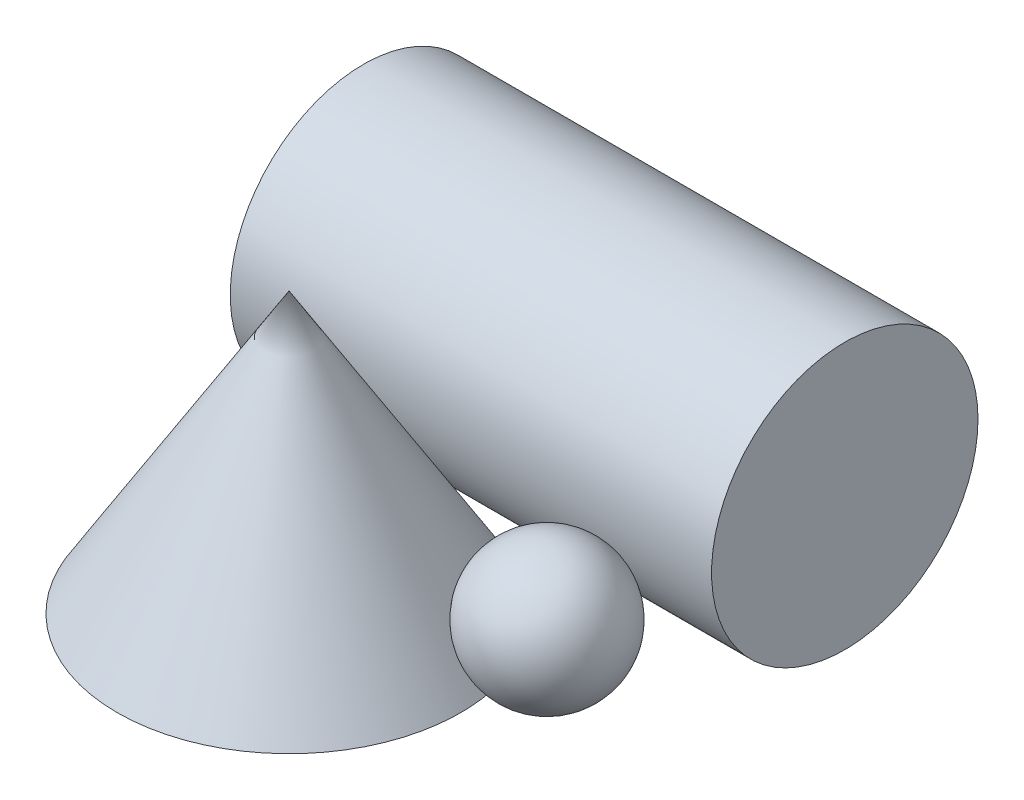
from build123d import *

# Parameters (mm, degrees)
SKETCH2_R           = 31
EXTRUDE1_DEPTH      = 72
EXTRUDE1_DEPTH_BACK = 40


with BuildPart() as part:
    # Sketch1 → Revolve1 (revolve)
    with BuildSketch(Plane.XY, mode=Mode.PRIVATE) as revolve1_sk:
        Polygon((40, 0), (0, 0), (0, 65), align=None)
    revolve(revolve1_sk.sketch.rotate(Axis((0, 0, 0), (0, 1, 0)), 90), axis=Axis((0, 0, 0), (0, 1, 0)))  # turned: the seam where the file's is


with BuildPart() as body_2:
    # Sketch2 → Extrude1 (new body, two sides)
    with BuildSketch(Plane(origin=(0, 0, 0), x_dir=(0, 0, -1), z_dir=(1, 0, 0))) as extrude1_sk:
        with Locations((57.322651015, 31)):
            Circle(SKETCH2_R)
    extrude(amount=EXTRUDE1_DEPTH)
    extrude(extrude1_sk.sketch, amount=-EXTRUDE1_DEPTH_BACK)


with BuildPart() as body_3:
    # Sketch6 → Revolve2 (revolve)
    with BuildSketch(Plane(origin=(0, 16, 0), x_dir=(-1, 0, 0), z_dir=(0, 1, 0))):
        with BuildLine():
            Line((-63.24248379, -12.780536112), (-31.24248379, -12.780536112))
            ThreePointArc((-31.24248379, -12.780536112), (-47.24248379, -28.780536112), (-63.24248379, -12.780536112))
        make_face()
    revolve(axis=Axis((63.24248379, 16, -12.780536112), (-1, 0, 0)))


solid = Compound([part.part, body_2.part, body_3.part])
